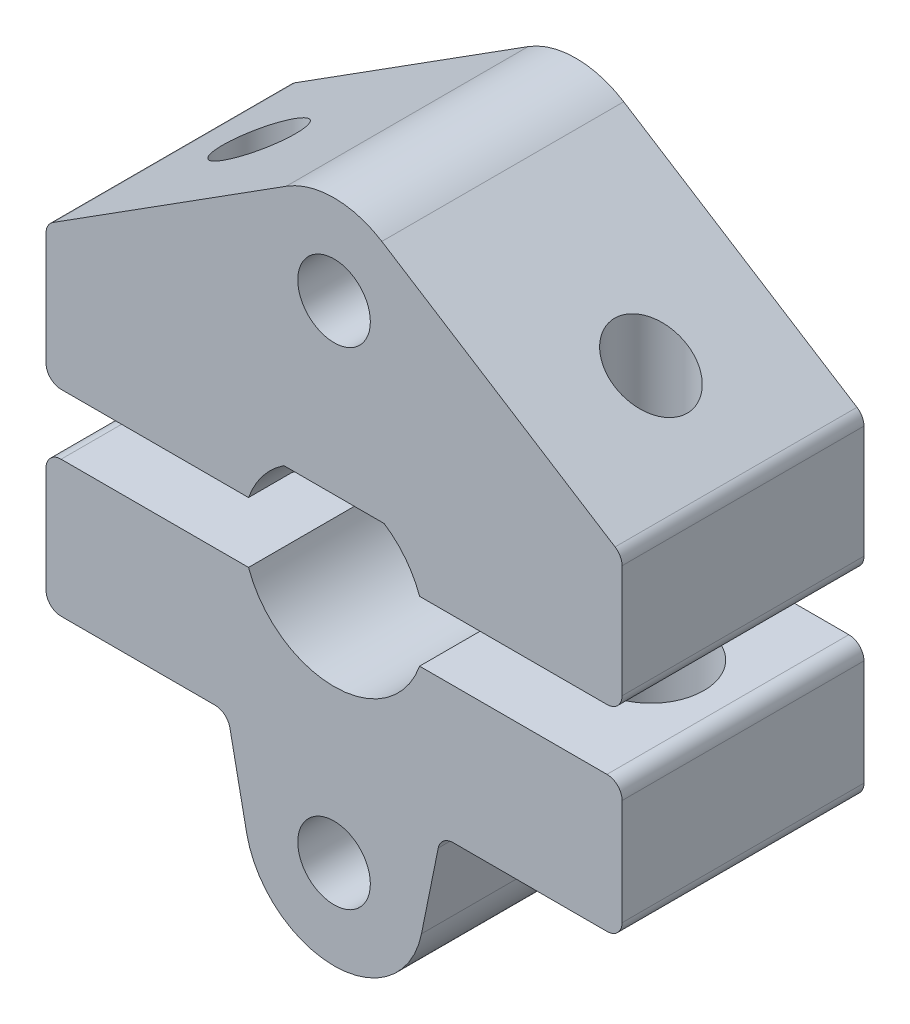
from build123d import *

# Parameters (mm, degrees)
SKETCH_1_R          = 1.2
EXTRUDE_1_DEPTH     = 8
EXTRUDE_1_2_DEPTH   = 8
SKETCH_2_R          = 1.2
CUT_EXTRUDE_1_DEPTH = 17.5
SKETCH_3_R          = 1.75
CUT_EXTRUDE_2_DEPTH = 4.5


with BuildPart() as part:
    # 草图1 → 凸台-拉伸1 (new body)
    with BuildSketch(Plane.XY):
        with BuildLine():
            Line((-1.658312395, 2.5), (1.658312395, 2.5))
            ThreePointArc((1.658312395, 2.5), (2.365419176, 1.84520788), (2.828427125, 1))
            Line((2.828427125, 1), (9.026279442, 1))
            ThreePointArc((9.026279442, 1), (9.379832832, 1.146446609), (9.526279442, 1.5))
            Line((9.526279442, 1.5), (9.526279442, 5.22507425))
            ThreePointArc((9.526279442, 5.22507425), (9.464414867, 5.465983671), (9.294130046, 5.647278056))
            Line((9.294130046, 5.647278056), (1.580318565, 10.541002455))
            ThreePointArc((1.580318565, 10.541002455), (0, 11), (-1.580318565, 10.541002455))
            Line((-1.580318565, 10.541002455), (-9.294130046, 5.647278056))
            ThreePointArc((-9.294130046, 5.647278056), (-9.464414867, 5.465983671), (-9.526279442, 5.22507425))
            Line((-9.526279442, 5.22507425), (-9.526279442, 1.5))
            ThreePointArc((-9.526279442, 1.5), (-9.379832832, 1.146446609), (-9.026279442, 1))
            Line((-9.026279442, 1), (-2.828427125, 1))
            ThreePointArc((-2.828427125, 1), (-2.365419176, 1.84520788), (-1.658312395, 2.5))
        make_face()
        with Locations((0, 8.05)):
            Circle(SKETCH_1_R, mode=Mode.SUBTRACT)
    extrude(amount=EXTRUDE_1_DEPTH)


with BuildPart() as body_2:
    # 草图1 → Extrude 1 2 (new body)
    with BuildSketch(Plane.XY):
        with BuildLine():
            Line((-9.026279442, -1), (-2.828427125, -1))
            ThreePointArc((-2.828427125, -1), (0, -3), (2.828427125, -1))
            Line((2.828427125, -1), (9.026279442, -1))
            ThreePointArc((9.026279442, -1), (9.379832832, -1.146446609), (9.526279442, -1.5))
            Line((9.526279442, -1.5), (9.526279442, -5))
            ThreePointArc((9.526279442, -5), (9.379832832, -5.353553391), (9.026279442, -5.5))
            Line((9.026279442, -5.5), (3.935174447, -5.5))
            ThreePointArc((3.935174447, -5.5), (3.6186464, -5.612947037), (3.445121974, -5.900760016))
            Line((3.445121974, -5.900760016), (2.891309587, -8.635515904))
            ThreePointArc((2.891309587, -8.635515904), (0, -11), (-2.891309587, -8.635515904))
            Line((-2.891309587, -8.635515904), (-3.445121974, -5.900760016))
            ThreePointArc((-3.445121974, -5.900760016), (-3.6186464, -5.612947037), (-3.935174447, -5.5))
            Line((-3.935174447, -5.5), (-9.026279442, -5.5))
            ThreePointArc((-9.026279442, -5.5), (-9.379832832, -5.353553391), (-9.526279442, -5))
            Line((-9.526279442, -5), (-9.526279442, -1.5))
            ThreePointArc((-9.526279442, -1.5), (-9.379832832, -1.146446609), (-9.026279442, -1))
        make_face()
        with Locations((0, -8.05)):
            Circle(SKETCH_1_R, mode=Mode.SUBTRACT)
    extrude(amount=EXTRUDE_1_2_DEPTH)


with BuildPart() as cut_extrude_1_tool:
    # 草图2 → 切除-拉伸1 (new body, through all)
    with BuildSketch(Plane.XZ.offset(5.5)):
        with Locations((6.480726944, 4)):
            Circle(SKETCH_2_R)
        with Locations((-6.480726944, 4)):
            Circle(SKETCH_2_R)
    extrude(amount=-CUT_EXTRUDE_1_DEPTH)


with BuildPart() as part_1:
    add(part.part)

    # 切除-拉伸1: cut by cut_extrude_1_tool
    add(cut_extrude_1_tool.part, mode=Mode.SUBTRACT)


with BuildPart() as body_2_1:
    add(body_2.part)

    # 切除-拉伸1: cut by cut_extrude_1_tool
    add(cut_extrude_1_tool.part, mode=Mode.SUBTRACT)

    # 草图3 → 切除-拉伸2 (cut)
    with BuildSketch(Plane.XZ.offset(5.5)):
        with Locations((-6.480726944, 4)):
            Circle(SKETCH_3_R)
        with Locations((6.480726944, 4)):
            Circle(SKETCH_3_R)
    extrude(amount=-CUT_EXTRUDE_2_DEPTH, mode=Mode.SUBTRACT)


solid = Compound([part_1.part, body_2_1.part])
